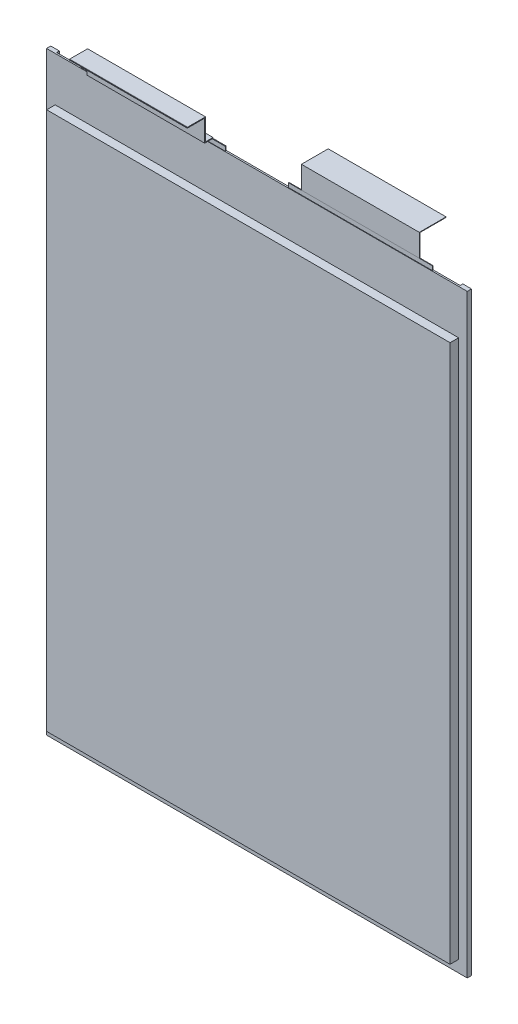
from build123d import *

# Parameters (mm, degrees)
SKETCH1_W                    = 160.6
SKETCH1_H                    = 227
INSULATION_DEPTH             = 0.3
INSULATION_DEPTH_BACK        = 0.3
SKETCH2_W                    = 154
SKETCH2_H                    = 205.5
MAIN_BODY_DEPTH              = 3.55
MAIN_BODY_DEPTH_BACK         = 3.55
SIDE_FOLDS_DEPTH             = 1.016
SKETCH6_W                    = 55
SKETCH6_H                    = 18.6
NEGATIVE_TAB_BASE_DEPTH      = 0.1
NEGATIVE_TAB_BASE_DEPTH_BACK = 0.1
SKETCH7_W                    = 55
SKETCH7_H                    = 18.6
POSITIVE_TAB_BASE_DEPTH      = 0.15
POSITIVE_TAB_BASE_DEPTH_BACK = 0.15
SKETCH110_W                  = 0.3
SKETCH110_H                  = 45
POSITIVE_TAB_DEPTH           = 23.650499994
SKETCH110_ON_SEGMENT_2_W     = 0.3
SKETCH110_ON_SEGMENT_2_H     = 45
POSITIVE_TAB_2_DEPTH         = 49.874449989
SKETCH110_ON_SEGMENT_3_W     = 0.3
SKETCH110_ON_SEGMENT_3_H     = 45
POSITIVE_TAB_3_DEPTH         = 55.260999989
SKETCH110_ON_SEGMENT_4_W     = 0.3
SKETCH110_ON_SEGMENT_4_H     = 45
POSITIVE_TAB_4_DEPTH         = 31.133774994
SKETCH110_ON_SEGMENT_5_W     = 0.3
SKETCH110_ON_SEGMENT_5_H     = 45
POSITIVE_TAB_5_DEPTH         = 1.15
SKETCH113_W                  = 0.2
SKETCH113_H                  = 45
NEGATIVE_TAB_DEPTH           = 31.960222221
SKETCH113_ON_SEGMENT_2_W     = 0.2
SKETCH113_ON_SEGMENT_2_H     = 45
NEGATIVE_TAB_2_DEPTH         = 33.621222221


with BuildPart() as part:
    # Sketch1 → Insulation (new, two sides)
    with BuildSketch(Plane.XY) as insulation_sk:
        Rectangle(SKETCH1_W, SKETCH1_H)
    extrude(amount=INSULATION_DEPTH)
    extrude(insulation_sk.sketch, amount=-INSULATION_DEPTH_BACK)

    # Sketch2 → Main Body (add, two sides)
    with BuildSketch(Plane.XY) as main_body_sk:
        with Locations((0, -6.25)):
            Rectangle(SKETCH2_W, SKETCH2_H)
    extrude(amount=MAIN_BODY_DEPTH)
    extrude(main_body_sk.sketch, amount=-MAIN_BODY_DEPTH_BACK)

    # Sketch5 → Side Folds (add)
    with BuildSketch(Plane(origin=(0, 0, -0.3), x_dir=(-1, 0, 0), z_dir=(0, 0, -1))):
        Polygon((-77, -109), (-77, 96.5), (-77, 113.5), (-80.3, 113.5), (-80.3, -113.5), (-77, -113.5), align=None)
        Polygon((77, 113.5), (77, 96.5), (77, -109), (77, -113.5), (80.3, -113.5), (80.3, 113.5), align=None)
    extrude(amount=SIDE_FOLDS_DEPTH)

    # Sketch6 → Negative Tab Base (add, two sides)
    with BuildSketch(Plane.XY) as negative_tab_base_sk:
        with Locations((39.3, 105.8)):
            Rectangle(SKETCH6_W, SKETCH6_H)
    extrude(amount=NEGATIVE_TAB_BASE_DEPTH)
    extrude(negative_tab_base_sk.sketch, amount=-NEGATIVE_TAB_BASE_DEPTH_BACK)

    # Sketch7 → Positive Tab Base (add, two sides)
    with BuildSketch(Plane.XY) as positive_tab_base_sk:
        with Locations((-39.7, 105.8)):
            Rectangle(SKETCH7_W, SKETCH7_H)
    extrude(amount=POSITIVE_TAB_BASE_DEPTH)
    extrude(positive_tab_base_sk.sketch, amount=-POSITIVE_TAB_BASE_DEPTH_BACK)


with BuildPart() as body_2:
    # Sketch110 → Positive Tab (new body)
    with BuildSketch(Plane(origin=(-39.7, 115.1, 0), x_dir=(0, 0, -1), z_dir=(0, 1, 0))):
        Rectangle(SKETCH110_W, SKETCH110_H)
    extrude(amount=POSITIVE_TAB_DEPTH)

    # Positive Tab mitre 1
    split(bisect_by=Plane(origin=(-39.7, 115.25, 0), x_dir=(1, 0, 0), z_dir=(0, -0.707106781, -0.707106781)), keep=Keep.TOP)


with BuildPart() as body_3:
    # Sketch110 on segment 2 (carried to segment 2) → Positive Tab 2 (new body)
    with BuildSketch(Plane(origin=(-39.7, 115.25, -23.500499994), x_dir=(0, 1, 0), z_dir=(0, 0, 1))):
        Rectangle(SKETCH110_ON_SEGMENT_2_W, SKETCH110_ON_SEGMENT_2_H)
    extrude(amount=POSITIVE_TAB_2_DEPTH)

    # Positive Tab 2 mitre 1
    split(bisect_by=Plane(origin=(-39.7, 115.25, 0), x_dir=(-1, 0, 0), z_dir=(0, 0.707106781, 0.707106781)), keep=Keep.TOP)

    # Positive Tab 2 mitre 2
    split(bisect_by=Plane(origin=(-39.7, 115.25, 2.87345), x_dir=(1, 0, 0), z_dir=(0, -0.707106781, -0.707106781)), keep=Keep.TOP)


with BuildPart() as body_4:
    # Sketch110 on segment 3 (carried to segment 3) → Positive Tab 3 (new body)
    with BuildSketch(Plane(origin=(-39.7, 91.749500006, 2.87345), x_dir=(0, 0, -1), z_dir=(0, 1, 0))):
        Rectangle(SKETCH110_ON_SEGMENT_3_W, SKETCH110_ON_SEGMENT_3_H)
    extrude(amount=POSITIVE_TAB_3_DEPTH)

    # Positive Tab 3 mitre 1
    split(bisect_by=Plane(origin=(-39.7, 115.25, 2.87345), x_dir=(-1, 0, 0), z_dir=(0, 0.707106781, 0.707106781)), keep=Keep.TOP)

    # Positive Tab 3 mitre 2
    split(bisect_by=Plane(origin=(-39.7, 123.51, 2.87345), x_dir=(1, 0, 0), z_dir=(0, -0.707106781, -0.707106781)), keep=Keep.TOP)


with BuildPart() as body_5:
    # Sketch110 on segment 4 (carried to segment 4) → Positive Tab 4 (new body)
    with BuildSketch(Plane(origin=(-39.7, 123.51, -20.627049994), x_dir=(0, 1, 0), z_dir=(0, 0, 1))):
        Rectangle(SKETCH110_ON_SEGMENT_4_W, SKETCH110_ON_SEGMENT_4_H)
    extrude(amount=POSITIVE_TAB_4_DEPTH)

    # Positive Tab 4 mitre 1
    split(bisect_by=Plane(origin=(-39.7, 123.51, 2.87345), x_dir=(-1, 0, 0), z_dir=(0, 0.707106781, 0.707106781)), keep=Keep.TOP)

    # Positive Tab 4 mitre 2
    split(bisect_by=Plane(origin=(-39.7, 123.51, 9.506725), x_dir=(0, 1, 0), z_dir=(0, 0, -1)), keep=Keep.TOP)


with BuildPart() as body_6:
    # Sketch110 on segment 5 (carried to segment 5) → Positive Tab 5 (new body)
    with BuildSketch(Plane(origin=(-39.7, 123.51, 8.506725), x_dir=(0, 1, 0), z_dir=(0, 0, 1))):
        Rectangle(SKETCH110_ON_SEGMENT_5_W, SKETCH110_ON_SEGMENT_5_H)
    extrude(amount=POSITIVE_TAB_5_DEPTH)

    # Positive Tab 5 mitre 1
    split(bisect_by=Plane(origin=(-39.7, 123.51, 9.506725), x_dir=(0, -1, 0), z_dir=(0, 0, 1)), keep=Keep.TOP)


with BuildPart() as body_7:
    # Sketch113 → Negative Tab (new body)
    with BuildSketch(Plane(origin=(39.3, 115.1, 0), x_dir=(0, 0, -1), z_dir=(0, 1, 0))):
        Rectangle(SKETCH113_W, SKETCH113_H)
    extrude(amount=NEGATIVE_TAB_DEPTH)

    # Negative Tab mitre 1
    split(bisect_by=Plane(origin=(39.3, 123.56, 0), x_dir=(1, 0, 0), z_dir=(0, -0.707106781, 0.707106781)), keep=Keep.TOP)


with BuildPart() as body_8:
    # Sketch113 on segment 2 (carried to segment 2) → Negative Tab 2 (new body)
    with BuildSketch(Plane(origin=(39.3, 123.56, 23.500222221), x_dir=(0, -1, 0), z_dir=(0, 0, -1))):
        Rectangle(SKETCH113_ON_SEGMENT_2_W, SKETCH113_ON_SEGMENT_2_H)
    extrude(amount=NEGATIVE_TAB_2_DEPTH)

    # Negative Tab 2 mitre 1
    split(bisect_by=Plane(origin=(39.3, 123.56, 0), x_dir=(-1, 0, 0), z_dir=(0, 0.707106781, -0.707106781)), keep=Keep.TOP)


solid = Compound([part.part, body_2.part, body_3.part, body_4.part, body_5.part, body_6.part, body_7.part, body_8.part])
